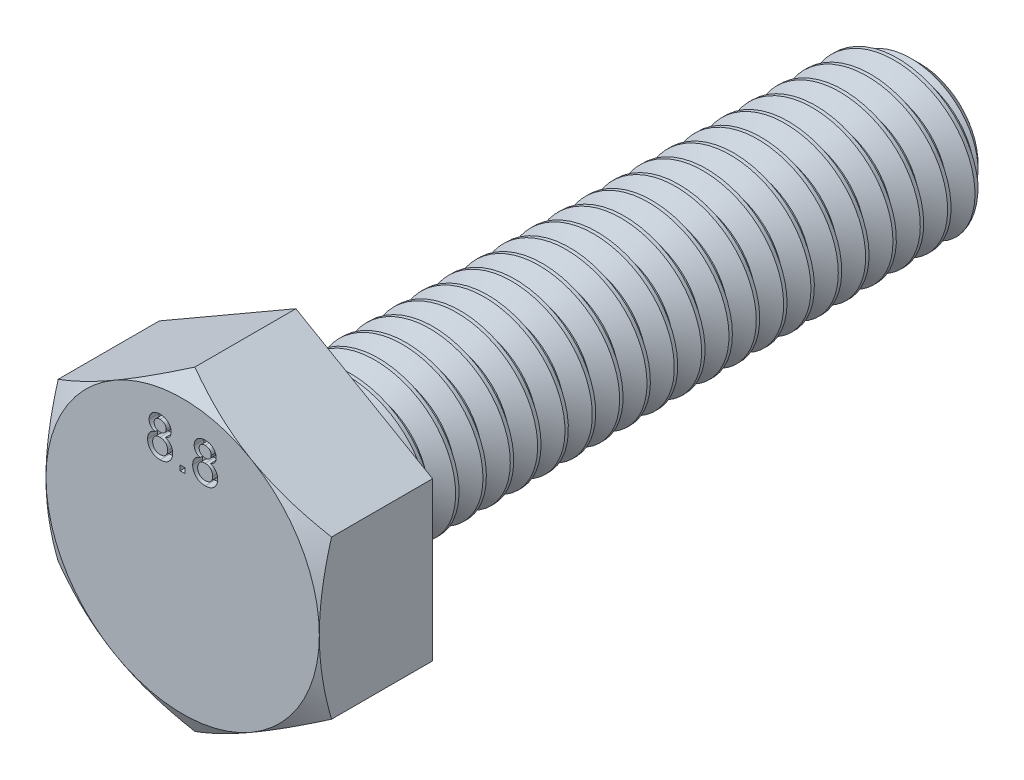
from build123d import *

# Parameters (mm, degrees)
BOSS_EXTRUDE1_DEPTH    = 2.9
SKETCH4_OUTSIDE_W      = 47.984
SKETCH4_OUTSIDE_H      = 49.066
SKETCH4_OUTSIDE_R      = 3.5
CUT_EXTRUDE2_DEPTH     = 10
CUT_EXTRUDE2_DRAFT     = -60
SKETCH10_W             = 0.128206
SKETCH10_H             = 0.128205
CUT_EXTRUDE5_DEPTH     = 0.25
CUT_SWEEP1_PITCH       = 0.7
CUT_SWEEP1_HEIGHT      = 16.7
CUT_SWEEP1_RADIUS      = 2
CUT_SWEEP1_START_ANGLE = 90
SKETCH9_OUTSIDE_W      = 15.444
SKETCH9_OUTSIDE_H      = 16.526
SKETCH9_OUTSIDE_R      = 1.469559
CUT_EXTRUDE4_DEPTH     = 1.05
CUT_EXTRUDE4_DRAFT     = -45


with BuildPart() as part:
    # Sketch2 → Revolve1 (revolve)
    with BuildSketch(Plane(origin=(0, 0, 0), x_dir=(0, 0, -1), z_dir=(1, 0, 0))):
        Polygon((9.45, 0), (-9.45, 0), (-9.45, 3.5), (-6.55, 3.5), (-6.55, 2), (9.45, 2), align=None)
    revolve(axis=Axis((0, 0, -9.45), (0, 0, 1)))


with BuildPart() as body_2:
    # Sketch3 → Boss-Extrude1 (new body)
    with BuildSketch(Plane.XY.offset(9.45)):
        Polygon((0, 4.041452), (-3.5, 2.020726), (-3.5, -2.020726), (0, -4.041452), (3.5, -2.020726), (3.5, 2.020726), align=None)
    extrude(amount=-BOSS_EXTRUDE1_DEPTH)


with BuildPart() as cut_extrude2_tool:
    # Sketch4 outside → Cut-Extrude2 (with draft: the straight prism first)
    with BuildSketch(Plane.XY.offset(9.45)):
        Rectangle(SKETCH4_OUTSIDE_W, SKETCH4_OUTSIDE_H)
        with Locations(Location((0, 0, 0), (0, 0, 90))):
            Circle(SKETCH4_OUTSIDE_R, mode=Mode.SUBTRACT)
    extrude(amount=-CUT_EXTRUDE2_DEPTH)
    # Cut-Extrude2: the draft: its side faces are tilted about the plane it starts from
    cut_extrude2_sides = [cut_extrude2_tool.faces().sort_by_distance(p)[0] for p in [
        (0, -24.533, 4.45),
        (23.992, 0, 4.45),
        (0, 24.533, 4.45),
        (-23.992, 0, 4.45),
        (0, -3.5, 4.45),
    ]]
    draft(cut_extrude2_sides, Plane.XY.offset(9.45), CUT_EXTRUDE2_DRAFT)


with BuildPart() as body_2_1:
    add(body_2.part)

    # Cut-Extrude2: cut by cut_extrude2_tool
    add(cut_extrude2_tool.part, mode=Mode.SUBTRACT)


with BuildPart() as cut_extrude5_tool:
    # Sketch10 → Cut-Extrude5 (new body)
    with BuildSketch(Plane.XY.offset(9.45)):
        with BuildLine():
            add(Edge.make_bspline(
                [(-0.707532, 2.4129), (-0.719696, 2.417659), (-0.74302, 2.426783), (-0.774477, 2.445043), (-0.8011, 2.466049), (-0.822563, 2.490307), (-0.838921, 2.517315), (-0.8507, 2.546731), (-0.857599, 2.578716), (-0.858507, 2.600833), (-0.858974, 2.612219)],
                knots=[0, 0, 0, 0, 1.162874, 2.229614, 3.228818, 4.17335, 5.100166, 6.029633, 6.985702, 8, 8, 8, 8], degree=3))
            add(Edge.make_bspline(
                [(-0.858974, 2.612219), (-0.858754, 2.620979), (-0.858323, 2.638177), (-0.854591, 2.663411), (-0.848615, 2.687591), (-0.840134, 2.71065), (-0.829508, 2.732777), (-0.816099, 2.753566), (-0.800688, 2.773606), (-0.782633, 2.792086), (-0.762738, 2.809011), (-0.741188, 2.824074), (-0.717819, 2.836391), (-0.69302, 2.846689), (-0.666668, 2.854752), (-0.638672, 2.860243), (-0.609129, 2.863735), (-0.588886, 2.86419), (-0.578526, 2.864422)],
                knots=[0, 0, 0, 0, 0.994102, 1.951453, 2.889124, 3.817216, 4.736004, 5.669744, 6.6205, 7.601567, 8.596478, 9.582687, 10.579762, 11.589152, 12.627475, 13.702347, 14.824124, 16, 16, 16, 16], degree=3))
            add(Edge.make_bspline(
                [(-0.578526, 2.864422), (-0.5681, 2.864187), (-0.547791, 2.86373), (-0.518091, 2.860284), (-0.489918, 2.854509), (-0.463288, 2.846315), (-0.43816, 2.835839), (-0.414698, 2.822962), (-0.392661, 2.807898), (-0.372612, 2.790466), (-0.35437, 2.77154), (-0.338565, 2.751264), (-0.325009, 2.730111), (-0.313807, 2.707953), (-0.305521, 2.684537), (-0.299204, 2.660304), (-0.29554, 2.634967), (-0.295097, 2.617773), (-0.294872, 2.609014)],
                knots=[0, 0, 0, 0, 1.171212, 2.281389, 3.353997, 4.398127, 5.40689, 6.407389, 7.40001, 8.400087, 9.387022, 10.349004, 11.283445, 12.206096, 13.131641, 14.068728, 15.016179, 16, 16, 16, 16], degree=3))
            add(Edge.make_bspline(
                [(-0.294872, 2.609014), (-0.295238, 2.598021), (-0.295957, 2.576465), (-0.303278, 2.545393), (-0.314689, 2.516386), (-0.331181, 2.489996), (-0.352067, 2.465952), (-0.377985, 2.44505), (-0.408542, 2.426818), (-0.431277, 2.417664), (-0.443109, 2.4129)],
                knots=[0, 0, 0, 0, 0.998681, 1.958225, 2.887912, 3.823713, 4.775377, 5.772726, 6.840783, 8, 8, 8, 8], degree=3))
            add(Edge.make_bspline(
                [(-0.443109, 2.4129), (-0.435643, 2.410366), (-0.421014, 2.4054), (-0.400333, 2.395745), (-0.380862, 2.385334), (-0.362492, 2.374064), (-0.345901, 2.361098), (-0.330535, 2.347201), (-0.316459, 2.332178), (-0.303865, 2.315901), (-0.292621, 2.298712), (-0.282995, 2.280569), (-0.27482, 2.26173), (-0.267833, 2.242107), (-0.26273, 2.221563), (-0.25916, 2.200192), (-0.256894, 2.178106), (-0.256573, 2.163106), (-0.25641, 2.155488)],
                knots=[0, 0, 0, 0, 1.104208, 2.163769, 3.193779, 4.198696, 5.179576, 6.140246, 7.100369, 8.060719, 9.021161, 9.975749, 10.935507, 11.897452, 12.891636, 13.897859, 14.932451, 16, 16, 16, 16], degree=3))
            add(Edge.make_bspline(
                [(-0.25641, 2.155488), (-0.256665, 2.144989), (-0.257167, 2.124304), (-0.261577, 2.093942), (-0.26825, 2.064776), (-0.27798, 2.036927), (-0.290407, 2.010377), (-0.30578, 1.985165), (-0.323947, 1.961315), (-0.344372, 1.938755), (-0.367208, 1.918361), (-0.391912, 1.90039), (-0.418577, 1.885337), (-0.446879, 1.872873), (-0.476954, 1.863213), (-0.508764, 1.856449), (-0.542297, 1.852422), (-0.565227, 1.851879), (-0.576923, 1.851602)],
                knots=[0, 0, 0, 0, 1.017598, 2.004746, 2.9691, 3.915171, 4.859469, 5.806714, 6.772805, 7.762837, 8.753335, 9.736397, 10.719438, 11.71679, 12.730405, 13.776888, 14.865954, 16, 16, 16, 16], degree=3))
            add(Edge.make_bspline(
                [(-0.576923, 1.851602), (-0.588618, 1.851885), (-0.611545, 1.852439), (-0.645109, 1.856385), (-0.676873, 1.863455), (-0.70691, 1.873124), (-0.735381, 1.885251), (-0.761867, 1.900643), (-0.786732, 1.918592), (-0.809584, 1.939112), (-0.830179, 1.96167), (-0.848106, 1.985871), (-0.863388, 2.011344), (-0.875964, 2.038232), (-0.88555, 2.066534), (-0.892278, 2.096146), (-0.896696, 2.127044), (-0.897186, 2.148127), (-0.897436, 2.158893)],
                knots=[0, 0, 0, 0, 1.127066, 2.209429, 3.250844, 4.25822, 5.246861, 6.227046, 7.204057, 8.197545, 9.181484, 10.142921, 11.095357, 12.039671, 12.998175, 13.969127, 14.962949, 16, 16, 16, 16], degree=3))
            add(Edge.make_bspline(
                [(-0.897436, 2.158893), (-0.897262, 2.16691), (-0.896921, 2.182639), (-0.894836, 2.205709), (-0.890682, 2.227698), (-0.885331, 2.248734), (-0.878537, 2.268871), (-0.870155, 2.287949), (-0.859986, 2.305924), (-0.848433, 2.322912), (-0.835351, 2.338794), (-0.820951, 2.35343), (-0.805182, 2.366655), (-0.788397, 2.378854), (-0.769893, 2.389164), (-0.750358, 2.398626), (-0.729457, 2.406695), (-0.714914, 2.410811), (-0.707532, 2.4129)],
                knots=[0, 0, 0, 0, 1.117345, 2.192424, 3.223717, 4.232639, 5.215561, 6.182181, 7.132172, 8.089791, 9.041831, 9.996006, 10.946863, 11.907506, 12.882866, 13.894318, 14.931263, 16, 16, 16, 16], degree=3))
        make_face()
        with BuildLine():
            add(Edge.make_bspline(
                [(-0.730769, 2.611618), (-0.730389, 2.601412), (-0.729653, 2.581689), (-0.721657, 2.553675), (-0.709152, 2.52851), (-0.694493, 2.510261), (-0.680439, 2.497827), (-0.668708, 2.489525), (-0.655889, 2.482477), (-0.641888, 2.476999), (-0.627045, 2.472146), (-0.610848, 2.469433), (-0.593677, 2.467228), (-0.581806, 2.467068), (-0.575721, 2.466986)],
                knots=[0, 0, 0, 0, 1.528727, 2.954179, 4.335216, 5.725683, 6.435919, 7.148063, 7.879427, 8.626027, 9.402979, 10.219054, 11.087118, 12, 12, 12, 12], degree=3))
            add(Edge.make_bspline(
                [(-0.575721, 2.466986), (-0.569771, 2.467071), (-0.558168, 2.467237), (-0.541383, 2.469397), (-0.525522, 2.472282), (-0.510819, 2.476654), (-0.497103, 2.482339), (-0.484598, 2.489348), (-0.47293, 2.497402), (-0.459288, 2.509931), (-0.444649, 2.527541), (-0.432103, 2.551582), (-0.424285, 2.577884), (-0.423487, 2.596204), (-0.423077, 2.605608)],
                knots=[0, 0, 0, 0, 0.922112, 1.798069, 2.620553, 3.419964, 4.171892, 4.918166, 5.639229, 6.365035, 7.785021, 9.165299, 10.544994, 12, 12, 12, 12], degree=3))
            add(Edge.make_bspline(
                [(-0.423077, 2.605608), (-0.42357, 2.615341), (-0.424536, 2.634385), (-0.432335, 2.661723), (-0.445466, 2.686484), (-0.460466, 2.704566), (-0.474349, 2.717666), (-0.486227, 2.726004), (-0.498995, 2.733101), (-0.512703, 2.738897), (-0.52737, 2.743571), (-0.543037, 2.746638), (-0.559636, 2.748789), (-0.571039, 2.748953), (-0.576923, 2.749038)],
                knots=[0, 0, 0, 0, 1.480633, 2.897216, 4.289383, 5.720567, 6.454675, 7.191245, 7.924225, 8.676083, 9.454506, 10.264321, 11.104479, 12, 12, 12, 12], degree=3))
            add(Edge.make_bspline(
                [(-0.576923, 2.749038), (-0.582807, 2.748956), (-0.594278, 2.748796), (-0.610986, 2.74658), (-0.626801, 2.743798), (-0.641577, 2.739333), (-0.655252, 2.733498), (-0.66797, 2.726397), (-0.679825, 2.718272), (-0.693806, 2.705756), (-0.708448, 2.688146), (-0.721348, 2.664489), (-0.72932, 2.638696), (-0.73028, 2.620755), (-0.730769, 2.611618)],
                knots=[0, 0, 0, 0, 0.91483, 1.783417, 2.618873, 3.41102, 4.17909, 4.927874, 5.674348, 6.410337, 7.841713, 9.213201, 10.580551, 12, 12, 12, 12], degree=3))
        make_face(mode=Mode.SUBTRACT)
        with BuildLine():
            add(Edge.make_bspline(
                [(-0.769231, 2.161297), (-0.769009, 2.153071), (-0.768565, 2.136597), (-0.76467, 2.112129), (-0.758062, 2.088116), (-0.749592, 2.064537), (-0.737645, 2.042342), (-0.721802, 2.022532), (-0.701922, 2.005877), (-0.679217, 1.991806), (-0.654441, 1.98073), (-0.628623, 1.973), (-0.602431, 1.967891), (-0.584759, 1.967288), (-0.575921, 1.966986)],
                knots=[0, 0, 0, 0, 0.957879, 1.918282, 2.876792, 3.856375, 4.831004, 5.799187, 6.792204, 7.836856, 8.902268, 9.943091, 10.971369, 12, 12, 12, 12], degree=3))
            add(Edge.make_bspline(
                [(-0.575921, 1.966986), (-0.568634, 1.96711), (-0.554477, 1.96735), (-0.53384, 1.97009), (-0.514395, 1.974248), (-0.496053, 1.97995), (-0.479085, 1.987749), (-0.463214, 1.996866), (-0.448601, 2.007884), (-0.435252, 2.020458), (-0.423302, 2.034367), (-0.413066, 2.049373), (-0.404137, 2.065052), (-0.396846, 2.081743), (-0.391574, 2.099481), (-0.387506, 2.117945), (-0.385052, 2.137327), (-0.384763, 2.15054), (-0.384615, 2.157291)],
                knots=[0, 0, 0, 0, 1.149387, 2.232932, 3.278774, 4.285225, 5.256757, 6.220082, 7.168479, 8.137608, 9.109141, 10.05619, 10.999892, 11.953253, 12.923241, 13.915357, 14.934853, 16, 16, 16, 16], degree=3))
            add(Edge.make_bspline(
                [(-0.384615, 2.157291), (-0.384768, 2.164175), (-0.385066, 2.177652), (-0.387457, 2.197459), (-0.391754, 2.216248), (-0.397279, 2.234303), (-0.404767, 2.251311), (-0.413755, 2.267515), (-0.424763, 2.282488), (-0.436833, 2.296738), (-0.450492, 2.309637), (-0.465577, 2.320761), (-0.481608, 2.330585), (-0.499071, 2.338121), (-0.51758, 2.344158), (-0.537225, 2.348544), (-0.558085, 2.351225), (-0.572374, 2.351474), (-0.579728, 2.351602)],
                knots=[0, 0, 0, 0, 1.065859, 2.086782, 3.082735, 4.047496, 5.006086, 5.955204, 6.910834, 7.878748, 8.84434, 9.812199, 10.776904, 11.749117, 12.749729, 13.788304, 14.86181, 16, 16, 16, 16], degree=3))
            add(Edge.make_bspline(
                [(-0.579728, 2.351602), (-0.586881, 2.351472), (-0.600905, 2.351219), (-0.621277, 2.348523), (-0.640564, 2.344382), (-0.658594, 2.338322), (-0.675595, 2.330748), (-0.691254, 2.321226), (-0.705851, 2.310172), (-0.718941, 2.297325), (-0.730752, 2.28337), (-0.740963, 2.268409), (-0.749984, 2.252791), (-0.756829, 2.236003), (-0.762623, 2.218587), (-0.766246, 2.200206), (-0.768821, 2.181068), (-0.769092, 2.167984), (-0.769231, 2.161297)],
                knots=[0, 0, 0, 0, 1.135239, 2.225423, 3.256957, 4.26278, 5.240265, 6.205774, 7.166381, 8.141101, 9.111719, 10.064571, 11.014055, 11.969087, 12.938083, 13.923698, 14.938921, 16, 16, 16, 16], degree=3))
        make_face(mode=Mode.SUBTRACT)
        with Locations((0, 1.928524)):
            Rectangle(SKETCH10_W, SKETCH10_H)
        with BuildLine():
            add(Edge.make_bspline(
                [(0.446314, 2.4129), (0.43415, 2.417659), (0.410827, 2.426783), (0.37937, 2.445043), (0.352746, 2.466049), (0.331283, 2.490307), (0.314925, 2.517315), (0.303146, 2.546731), (0.296247, 2.578716), (0.295339, 2.600833), (0.294872, 2.612219)],
                knots=[0, 0, 0, 0, 1.162874, 2.229614, 3.228818, 4.17335, 5.100166, 6.029633, 6.985702, 8, 8, 8, 8], degree=3))
            add(Edge.make_bspline(
                [(0.294872, 2.612219), (0.295092, 2.620979), (0.295524, 2.638177), (0.299255, 2.663411), (0.305231, 2.687591), (0.313713, 2.71065), (0.324339, 2.732777), (0.337747, 2.753566), (0.353159, 2.773606), (0.371213, 2.792086), (0.391108, 2.809011), (0.412658, 2.824074), (0.436027, 2.836391), (0.460826, 2.846689), (0.487178, 2.854752), (0.515174, 2.860243), (0.544717, 2.863735), (0.56496, 2.86419), (0.575321, 2.864422)],
                knots=[0, 0, 0, 0, 0.994102, 1.951453, 2.889124, 3.817216, 4.736004, 5.669744, 6.6205, 7.601567, 8.596478, 9.582687, 10.579762, 11.589152, 12.627475, 13.702347, 14.824124, 16, 16, 16, 16], degree=3))
            add(Edge.make_bspline(
                [(0.575321, 2.864422), (0.585747, 2.864187), (0.606055, 2.86373), (0.635755, 2.860284), (0.663928, 2.854509), (0.690558, 2.846315), (0.715686, 2.835839), (0.739148, 2.822962), (0.761186, 2.807898), (0.781234, 2.790466), (0.799477, 2.77154), (0.815282, 2.751264), (0.828837, 2.730111), (0.840039, 2.707953), (0.848326, 2.684537), (0.854642, 2.660304), (0.858306, 2.634967), (0.858749, 2.617773), (0.858974, 2.609014)],
                knots=[0, 0, 0, 0, 1.171212, 2.281389, 3.353997, 4.398127, 5.40689, 6.407389, 7.40001, 8.400087, 9.387022, 10.349004, 11.283445, 12.206096, 13.131641, 14.068728, 15.016179, 16, 16, 16, 16], degree=3))
            add(Edge.make_bspline(
                [(0.858974, 2.609014), (0.858608, 2.598021), (0.85789, 2.576465), (0.850568, 2.545393), (0.839158, 2.516386), (0.822666, 2.489996), (0.801779, 2.465952), (0.775861, 2.44505), (0.745304, 2.426818), (0.72257, 2.417664), (0.710737, 2.4129)],
                knots=[0, 0, 0, 0, 0.998681, 1.958225, 2.887912, 3.823713, 4.775377, 5.772726, 6.840783, 8, 8, 8, 8], degree=3))
            add(Edge.make_bspline(
                [(0.710737, 2.4129), (0.718203, 2.410366), (0.732832, 2.4054), (0.753513, 2.395745), (0.772984, 2.385334), (0.791354, 2.374064), (0.807945, 2.361098), (0.823311, 2.347201), (0.837387, 2.332178), (0.849981, 2.315901), (0.861225, 2.298712), (0.870851, 2.280569), (0.879026, 2.26173), (0.886013, 2.242107), (0.891116, 2.221563), (0.894687, 2.200192), (0.896952, 2.178106), (0.897273, 2.163106), (0.897436, 2.155488)],
                knots=[0, 0, 0, 0, 1.104208, 2.163769, 3.193779, 4.198696, 5.179576, 6.140246, 7.100369, 8.060719, 9.021161, 9.975749, 10.935507, 11.897452, 12.891636, 13.897859, 14.932451, 16, 16, 16, 16], degree=3))
            add(Edge.make_bspline(
                [(0.897436, 2.155488), (0.897181, 2.144989), (0.896679, 2.124304), (0.892269, 2.093942), (0.885596, 2.064776), (0.875867, 2.036927), (0.863439, 2.010377), (0.848067, 1.985165), (0.8299, 1.961315), (0.809474, 1.938755), (0.786638, 1.918361), (0.761935, 1.90039), (0.73527, 1.885337), (0.706967, 1.872873), (0.676892, 1.863213), (0.645082, 1.856449), (0.611549, 1.852422), (0.58862, 1.851879), (0.576923, 1.851602)],
                knots=[0, 0, 0, 0, 1.017598, 2.004746, 2.9691, 3.915171, 4.859469, 5.806714, 6.772805, 7.762837, 8.753335, 9.736397, 10.719438, 11.71679, 12.730405, 13.776888, 14.865954, 16, 16, 16, 16], degree=3))
            add(Edge.make_bspline(
                [(0.576923, 1.851602), (0.565228, 1.851885), (0.542301, 1.852439), (0.508737, 1.856385), (0.476973, 1.863455), (0.446936, 1.873124), (0.418465, 1.885251), (0.391979, 1.900643), (0.367114, 1.918592), (0.344262, 1.939112), (0.323667, 1.96167), (0.30574, 1.985871), (0.290458, 2.011344), (0.277882, 2.038232), (0.268296, 2.066534), (0.261569, 2.096146), (0.25715, 2.127044), (0.25666, 2.148127), (0.25641, 2.158893)],
                knots=[0, 0, 0, 0, 1.127066, 2.209429, 3.250844, 4.25822, 5.246861, 6.227046, 7.204057, 8.197545, 9.181484, 10.142921, 11.095357, 12.039671, 12.998175, 13.969127, 14.962949, 16, 16, 16, 16], degree=3))
            add(Edge.make_bspline(
                [(0.25641, 2.158893), (0.256584, 2.16691), (0.256925, 2.182639), (0.25901, 2.205709), (0.263164, 2.227698), (0.268515, 2.248734), (0.275309, 2.268871), (0.283691, 2.287949), (0.29386, 2.305924), (0.305413, 2.322912), (0.318495, 2.338794), (0.332895, 2.35343), (0.348665, 2.366655), (0.365449, 2.378854), (0.383953, 2.389164), (0.403488, 2.398626), (0.424389, 2.406695), (0.438933, 2.410811), (0.446314, 2.4129)],
                knots=[0, 0, 0, 0, 1.117345, 2.192424, 3.223717, 4.232639, 5.215561, 6.182181, 7.132172, 8.089791, 9.041831, 9.996006, 10.946863, 11.907506, 12.882866, 13.894318, 14.931263, 16, 16, 16, 16], degree=3))
        make_face()
        with BuildLine():
            add(Edge.make_bspline(
                [(0.423077, 2.611618), (0.423457, 2.601412), (0.424193, 2.581689), (0.432189, 2.553675), (0.444694, 2.52851), (0.459353, 2.510261), (0.473408, 2.497827), (0.485138, 2.489525), (0.497957, 2.482477), (0.511958, 2.476999), (0.526801, 2.472146), (0.542998, 2.469433), (0.560169, 2.467228), (0.57204, 2.467068), (0.578125, 2.466986)],
                knots=[0, 0, 0, 0, 1.528727, 2.954179, 4.335216, 5.725683, 6.435919, 7.148063, 7.879427, 8.626027, 9.402979, 10.219054, 11.087118, 12, 12, 12, 12], degree=3))
            add(Edge.make_bspline(
                [(0.578125, 2.466986), (0.584075, 2.467071), (0.595678, 2.467237), (0.612463, 2.469397), (0.628324, 2.472282), (0.643028, 2.476654), (0.656743, 2.482339), (0.669248, 2.489348), (0.680916, 2.497402), (0.694558, 2.509931), (0.709197, 2.527541), (0.721743, 2.551582), (0.729562, 2.577884), (0.73036, 2.596204), (0.730769, 2.605608)],
                knots=[0, 0, 0, 0, 0.922112, 1.798069, 2.620553, 3.419964, 4.171892, 4.918166, 5.639229, 6.365035, 7.785021, 9.165299, 10.544994, 12, 12, 12, 12], degree=3))
            add(Edge.make_bspline(
                [(0.730769, 2.605608), (0.730276, 2.615341), (0.72931, 2.634385), (0.721511, 2.661723), (0.70838, 2.686484), (0.69338, 2.704566), (0.679497, 2.717666), (0.667619, 2.726004), (0.654851, 2.733101), (0.641143, 2.738897), (0.626476, 2.743571), (0.61081, 2.746638), (0.59421, 2.748789), (0.582807, 2.748953), (0.576923, 2.749038)],
                knots=[0, 0, 0, 0, 1.480633, 2.897216, 4.289383, 5.720567, 6.454675, 7.191245, 7.924225, 8.676083, 9.454506, 10.264321, 11.104479, 12, 12, 12, 12], degree=3))
            add(Edge.make_bspline(
                [(0.576923, 2.749038), (0.571039, 2.748956), (0.559568, 2.748796), (0.54286, 2.74658), (0.527045, 2.743798), (0.51227, 2.739333), (0.498594, 2.733498), (0.485876, 2.726397), (0.474021, 2.718272), (0.46004, 2.705756), (0.445398, 2.688146), (0.432498, 2.664489), (0.424526, 2.638696), (0.423566, 2.620755), (0.423077, 2.611618)],
                knots=[0, 0, 0, 0, 0.91483, 1.783417, 2.618873, 3.41102, 4.17909, 4.927874, 5.674348, 6.410337, 7.841713, 9.213201, 10.580551, 12, 12, 12, 12], degree=3))
        make_face(mode=Mode.SUBTRACT)
        with BuildLine():
            add(Edge.make_bspline(
                [(0.384615, 2.161297), (0.384837, 2.153071), (0.385281, 2.136597), (0.389176, 2.112129), (0.395784, 2.088116), (0.404254, 2.064537), (0.416201, 2.042342), (0.432044, 2.022532), (0.451924, 2.005877), (0.474629, 1.991806), (0.499405, 1.98073), (0.525223, 1.973), (0.551415, 1.967891), (0.569087, 1.967288), (0.577925, 1.966986)],
                knots=[0, 0, 0, 0, 0.957879, 1.918282, 2.876792, 3.856375, 4.831004, 5.799187, 6.792204, 7.836856, 8.902268, 9.943091, 10.971369, 12, 12, 12, 12], degree=3))
            add(Edge.make_bspline(
                [(0.577925, 1.966986), (0.585212, 1.96711), (0.599369, 1.96735), (0.620006, 1.97009), (0.639451, 1.974248), (0.657793, 1.97995), (0.674761, 1.987749), (0.690633, 1.996866), (0.705245, 2.007884), (0.718594, 2.020458), (0.730544, 2.034367), (0.74078, 2.049373), (0.74971, 2.065052), (0.757, 2.081743), (0.762272, 2.099481), (0.76634, 2.117945), (0.768795, 2.137327), (0.769083, 2.15054), (0.769231, 2.157291)],
                knots=[0, 0, 0, 0, 1.149387, 2.232932, 3.278774, 4.285225, 5.256757, 6.220082, 7.168479, 8.137608, 9.109141, 10.05619, 10.999892, 11.953253, 12.923241, 13.915357, 14.934853, 16, 16, 16, 16], degree=3))
            add(Edge.make_bspline(
                [(0.769231, 2.157291), (0.769079, 2.164175), (0.768781, 2.177652), (0.766389, 2.197459), (0.762092, 2.216248), (0.756567, 2.234303), (0.749079, 2.251311), (0.740091, 2.267515), (0.729084, 2.282488), (0.717013, 2.296738), (0.703354, 2.309637), (0.68827, 2.320761), (0.672239, 2.330585), (0.654776, 2.338121), (0.636266, 2.344158), (0.616621, 2.348544), (0.595761, 2.351225), (0.581472, 2.351474), (0.574119, 2.351602)],
                knots=[0, 0, 0, 0, 1.065859, 2.086782, 3.082735, 4.047496, 5.006086, 5.955204, 6.910834, 7.878748, 8.84434, 9.812199, 10.776904, 11.749117, 12.749729, 13.788304, 14.86181, 16, 16, 16, 16], degree=3))
            add(Edge.make_bspline(
                [(0.574119, 2.351602), (0.566965, 2.351472), (0.552941, 2.351219), (0.532569, 2.348523), (0.513283, 2.344382), (0.495252, 2.338322), (0.478251, 2.330748), (0.462592, 2.321226), (0.447995, 2.310172), (0.434905, 2.297325), (0.423095, 2.28337), (0.412883, 2.268409), (0.403863, 2.252791), (0.397017, 2.236003), (0.391223, 2.218587), (0.387601, 2.200206), (0.385026, 2.181068), (0.384754, 2.167984), (0.384615, 2.161297)],
                knots=[0, 0, 0, 0, 1.135239, 2.225423, 3.256957, 4.26278, 5.240265, 6.205774, 7.166381, 8.141101, 9.111719, 10.064571, 11.014055, 11.969087, 12.938083, 13.923698, 14.938921, 16, 16, 16, 16], degree=3))
        make_face(mode=Mode.SUBTRACT)
    extrude(amount=-CUT_EXTRUDE5_DEPTH)


with BuildPart() as part_1:
    add(part.part)

    # Cut-Extrude5: cut by cut_extrude5_tool
    add(cut_extrude5_tool.part, mode=Mode.SUBTRACT)

    # Cut-Sweep1: sweep along a helix
    with BuildLine() as cut_sweep1_path:
        add(Helix(CUT_SWEEP1_PITCH, CUT_SWEEP1_HEIGHT, CUT_SWEEP1_RADIUS, center=(0, 0, -9.45), direction=(0, 0, 1), mode=Mode.PRIVATE).rotate(Axis((0, 0, -9.45), (0, 0, 1)), CUT_SWEEP1_START_ANGLE))
    # Sketch7 → Cut-Sweep1 (sweep, cut)
    with BuildSketch(Plane(origin=(0, 0, 0), x_dir=(0, 0, -1), z_dir=(1, 0, 0))):
        Polygon((9.7125, 1.545337), (9.8, 1.545337), (10.084375, 2.037889), (9.428125, 2.037889), align=None)
    sweep(path=cut_sweep1_path.line, is_frenet=True, mode=Mode.SUBTRACT)

    # Sketch8 → Revolve2 (revolve)
    with BuildSketch(Plane(origin=(0, 0, 0), x_dir=(0, 0, -1), z_dir=(1, 0, 0))):
        Polygon((-6.55, 2), (-5.85, 1.533333), (-6.55, 1.533333), align=None)
    revolve(axis=Axis((0, 0, -9.45), (0, 0, 1)))


with BuildPart() as body_2_2:
    add(body_2_1.part)

    # Cut-Extrude5: cut by cut_extrude5_tool
    add(cut_extrude5_tool.part, mode=Mode.SUBTRACT)


with BuildPart() as cut_extrude4_tool:
    # Sketch9 outside → Cut-Extrude4 (with draft: the straight prism first)
    with BuildSketch(Plane(origin=(0, 0, -9.45), x_dir=(-1, 0, 0), z_dir=(0, 0, -1))):
        Rectangle(SKETCH9_OUTSIDE_W, SKETCH9_OUTSIDE_H)
        Circle(SKETCH9_OUTSIDE_R, mode=Mode.SUBTRACT)
    extrude(amount=-CUT_EXTRUDE4_DEPTH)
    # Cut-Extrude4: the draft: its side faces are tilted about the plane it starts from
    cut_extrude4_sides = [cut_extrude4_tool.faces().sort_by_distance(p)[0] for p in [
        (0, -8.263, -8.925),
        (-7.722, 0, -8.925),
        (0, 8.263, -8.925),
        (7.722, 0, -8.925),
        (1.469559, 0, -8.925),
    ]]
    draft(cut_extrude4_sides, Plane(origin=(0, 0, -9.45), x_dir=(-1, 0, 0), z_dir=(0, 0, -1)), CUT_EXTRUDE4_DRAFT)


with BuildPart() as part_2:
    add(part_1.part)

    # Cut-Extrude4: cut by cut_extrude4_tool
    add(cut_extrude4_tool.part, mode=Mode.SUBTRACT)

    # Combine1: union body 2
    add(body_2_2.part)


solid = part_2.part
